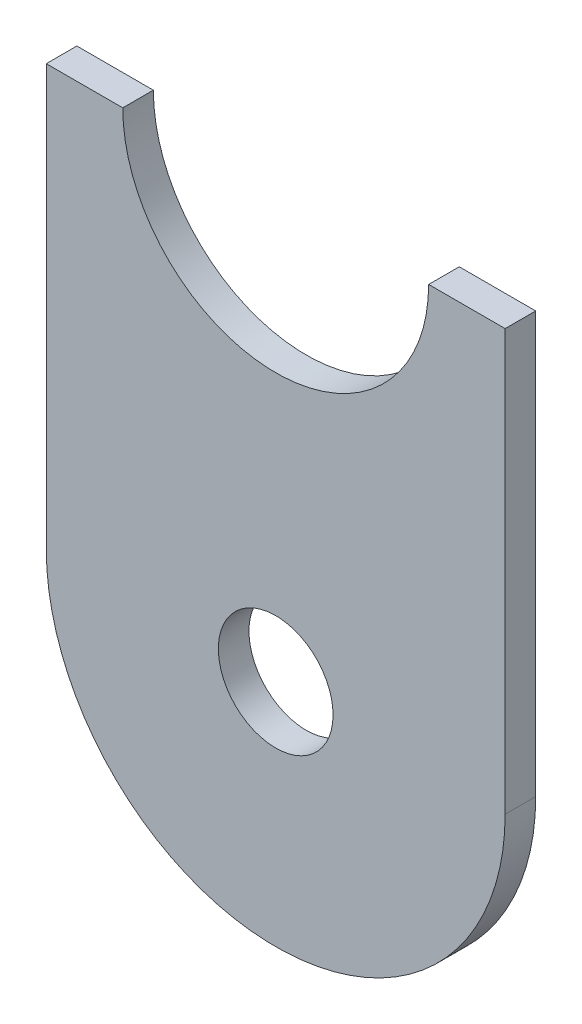
from build123d import *

# Parameters (mm, degrees)
SKETCH1_R           = 4.7625
BOSS_EXTRUDE1_DEPTH = 2.54


with BuildPart() as part:
    # Sketch1 → Boss-Extrude1 (new body)
    with BuildSketch(Plane.XY):
        with BuildLine():
            Line((-19.05, 34.925), (-19.05, -3e-09))
            ThreePointArc((-19.05, -3e-09), (2e-09, -19.05), (19.05, 0))
            Line((19.05, 0), (19.05, 34.925))
            Line((19.05, 34.925), (12.7, 34.925))
            ThreePointArc((12.7, 34.925), (0, 22.225), (-12.7, 34.925))
            Line((-12.7, 34.925), (-19.05, 34.925))
        make_face()
        Circle(SKETCH1_R, mode=Mode.SUBTRACT)
    extrude(amount=BOSS_EXTRUDE1_DEPTH)


solid = part.part
